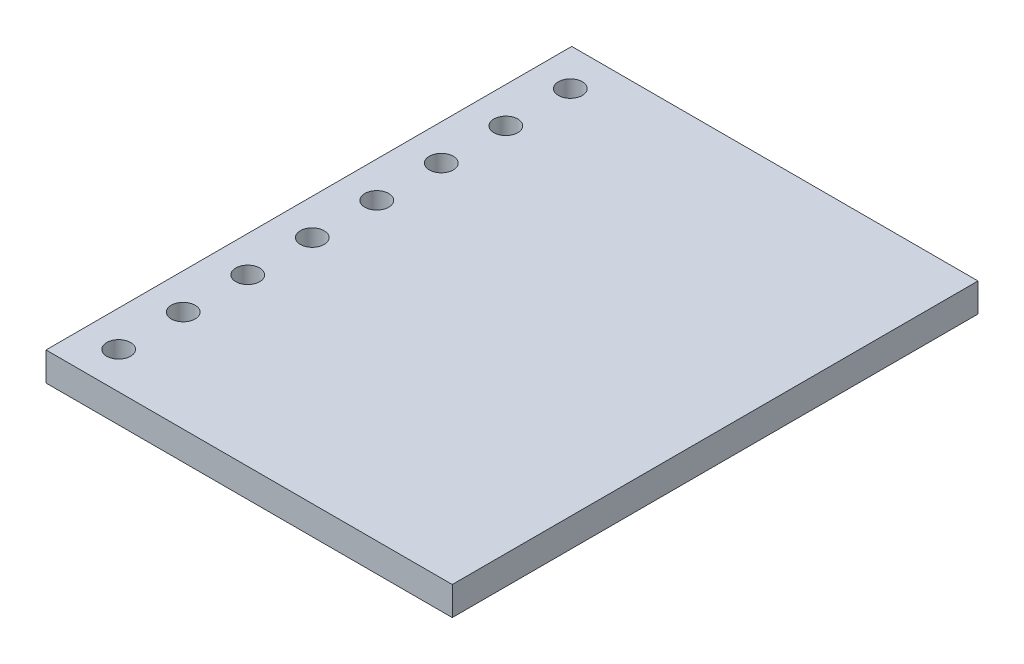
from build123d import *

# Parameters (mm, degrees)
SKETCH1_W           = 17
SKETCH1_H           = 22
SKETCH1_R           = 0.5
BOSS_EXTRUDE1_DEPTH = 1.2


with BuildPart() as part:
    # Sketch1 → Boss-Extrude1 (new body)
    with BuildSketch(Plane(origin=(0, 0, 0), x_dir=(1, 0, 0), z_dir=(0, 1, 0))):
        with Locations((8.5, 11)):
            Rectangle(SKETCH1_W, SKETCH1_H)
        with Locations((1.5, 20.441808073)):
            Circle(SKETCH1_R, mode=Mode.SUBTRACT)
        with Locations((1.5, 17.741808073)):
            Circle(SKETCH1_R, mode=Mode.SUBTRACT)
        with Locations((1.5, 15.041808073)):
            Circle(SKETCH1_R, mode=Mode.SUBTRACT)
        with Locations((1.5, 12.341808073)):
            Circle(SKETCH1_R, mode=Mode.SUBTRACT)
        with Locations((1.5, 9.641808073)):
            Circle(SKETCH1_R, mode=Mode.SUBTRACT)
        with Locations((1.5, 6.941808073)):
            Circle(SKETCH1_R, mode=Mode.SUBTRACT)
        with Locations((1.5, 4.241808073)):
            Circle(SKETCH1_R, mode=Mode.SUBTRACT)
        with Locations((1.5, 1.541808073)):
            Circle(SKETCH1_R, mode=Mode.SUBTRACT)
    extrude(amount=BOSS_EXTRUDE1_DEPTH)


solid = part.part
